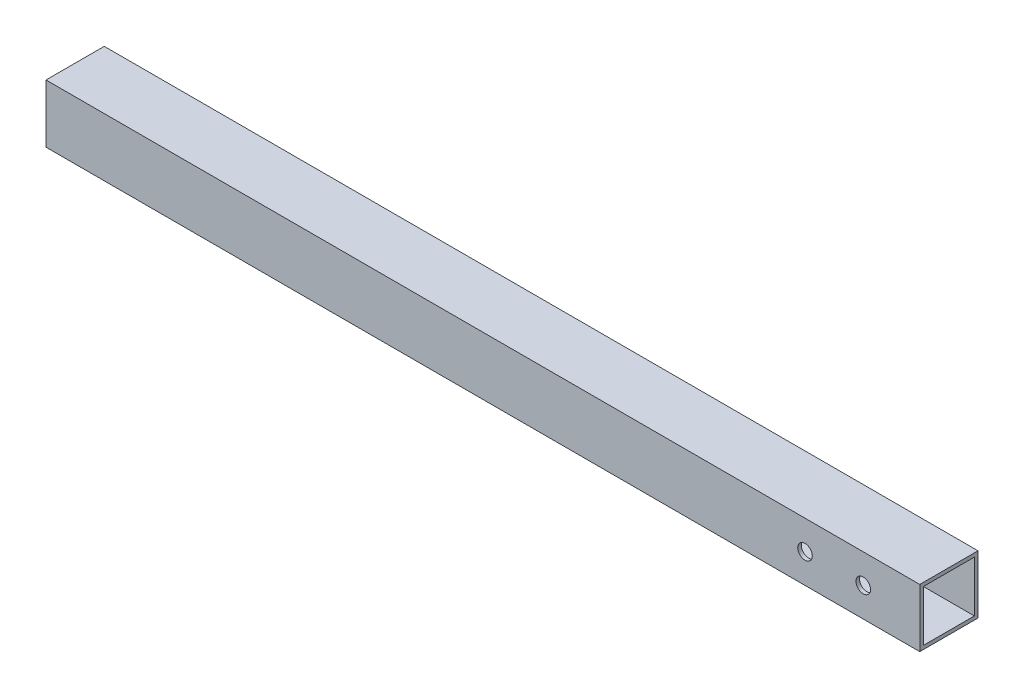
from build123d import *

# Parameters (mm, degrees)
SKETCH1_W           = 25.4
SKETCH1_H           = 25.4
SKETCH1_W_2         = 22.225
SKETCH1_H_2         = 22.225
BOSS_EXTRUDE1_DEPTH = 381
SKETCH2_R           = 3.175
CUT_EXTRUDE1_DEPTH  = 381


with BuildPart() as part:
    # Sketch1 → Boss-Extrude1 (new body)
    with BuildSketch(Plane(origin=(0, 0, 0), x_dir=(0, 0, -1), z_dir=(1, 0, 0))):
        Rectangle(SKETCH1_W, SKETCH1_H)
        Rectangle(SKETCH1_W_2, SKETCH1_H_2, mode=Mode.SUBTRACT)
    extrude(amount=BOSS_EXTRUDE1_DEPTH)

    # Sketch2 → Cut-Extrude1 (cut)
    with BuildSketch(Plane(origin=(0, 0, -12.7), x_dir=(-1, 0, 0), z_dir=(0, 0, -1))):
        with Locations((-356.362, 0)):
            Circle(SKETCH2_R)
        with Locations((-330.962, 0)):
            Circle(SKETCH2_R)
    extrude(amount=-CUT_EXTRUDE1_DEPTH, mode=Mode.SUBTRACT)


solid = part.part
